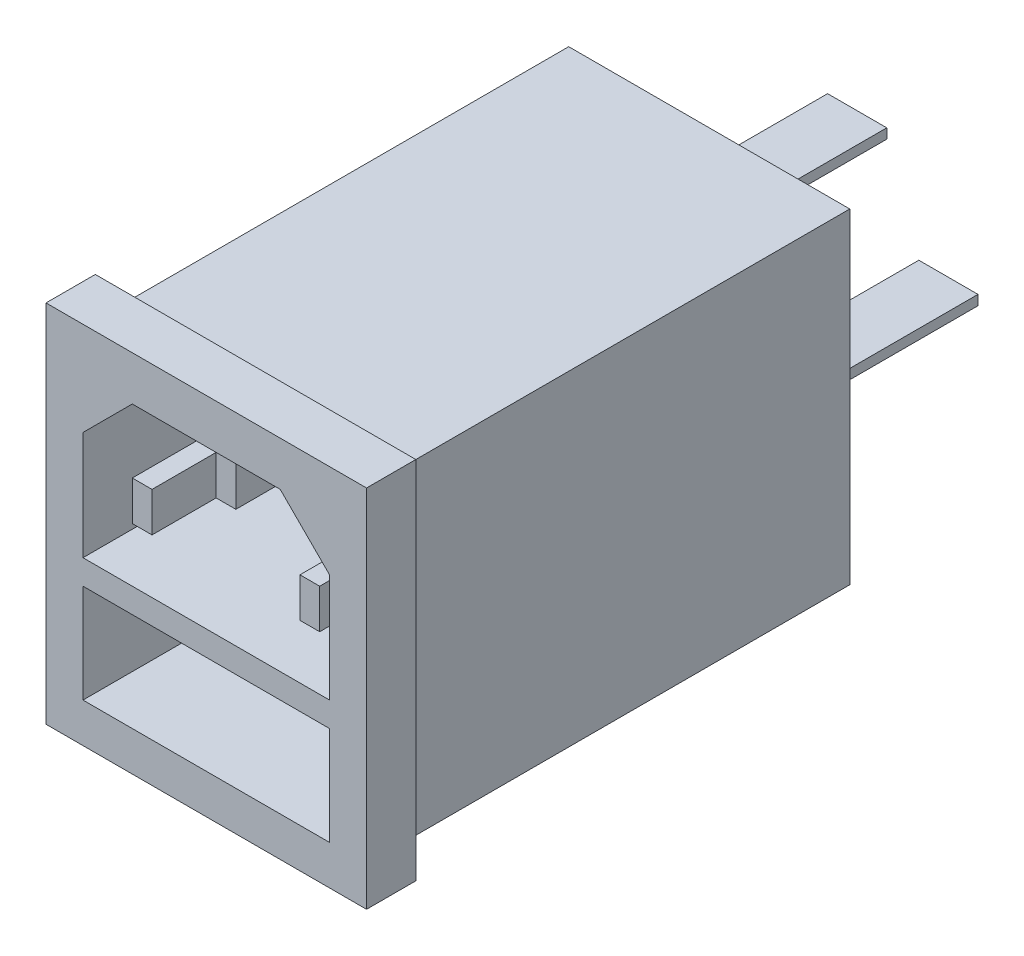
from build123d import *

# Parameters (mm, degrees)
SKETCH1_W           = 28.5
SKETCH1_H           = 33
BOSS_EXTRUDE1_DEPTH = 46
SKETCH2_W           = 32.5
SKETCH2_H           = 37
BOSS_EXTRUDE2_DEPTH = 5
SKETCH3_W           = 25
SKETCH3_H           = 10
CUT_EXTRUDE1_DEPTH  = 17
SKETCH4_W           = 2
SKETCH4_H           = 4
BOSS_EXTRUDE3_DEPTH = 15
SKETCH5_W           = 6
SKETCH5_H           = 1
BOSS_EXTRUDE4_DEPTH = 15


with BuildPart() as part:
    # Sketch1 → Boss-Extrude1 (new body)
    with BuildSketch(Plane.XY):
        Rectangle(SKETCH1_W, SKETCH1_H)
    extrude(amount=BOSS_EXTRUDE1_DEPTH)

    # Sketch2 → Boss-Extrude2 (add)
    with BuildSketch(Plane.XY.offset(46)):
        Rectangle(SKETCH2_W, SKETCH2_H)
    extrude(amount=BOSS_EXTRUDE2_DEPTH)

    # Sketch3 → Cut-Extrude1 (cut)
    with BuildSketch(Plane.XY.offset(51)):
        Polygon((12.5, -2), (-12.5, -2), (-12.5, 9), (-7.5, 14), (7.5, 14), (12.5, 9), align=None)
        with Locations((0, -9.5)):
            Rectangle(SKETCH3_W, SKETCH3_H)
    extrude(amount=-CUT_EXTRUDE1_DEPTH, mode=Mode.SUBTRACT)

    # Sketch4 → Boss-Extrude3 (add)
    with BuildSketch(Plane.XY.offset(34)):
        with Locations((-8.5, 3.5)):
            Rectangle(SKETCH4_W, SKETCH4_H)
        with Locations((0, 10)):
            Rectangle(SKETCH4_W, SKETCH4_H)
        with Locations((8.5, 3.5)):
            Rectangle(SKETCH4_W, SKETCH4_H)
    extrude(amount=BOSS_EXTRUDE3_DEPTH)

    # Sketch5 → Boss-Extrude4 (add)
    with BuildSketch(Plane(origin=(0, 0, 0), x_dir=(-1, 0, 0), z_dir=(0, 0, -1))):
        with Locations((-9.25, 0)):
            Rectangle(SKETCH5_W, SKETCH5_H)
        with Locations((0, 10)):
            Rectangle(SKETCH5_W, SKETCH5_H)
        with Locations((9.25, 0)):
            Rectangle(SKETCH5_W, SKETCH5_H)
    extrude(amount=BOSS_EXTRUDE4_DEPTH)


solid = part.part
